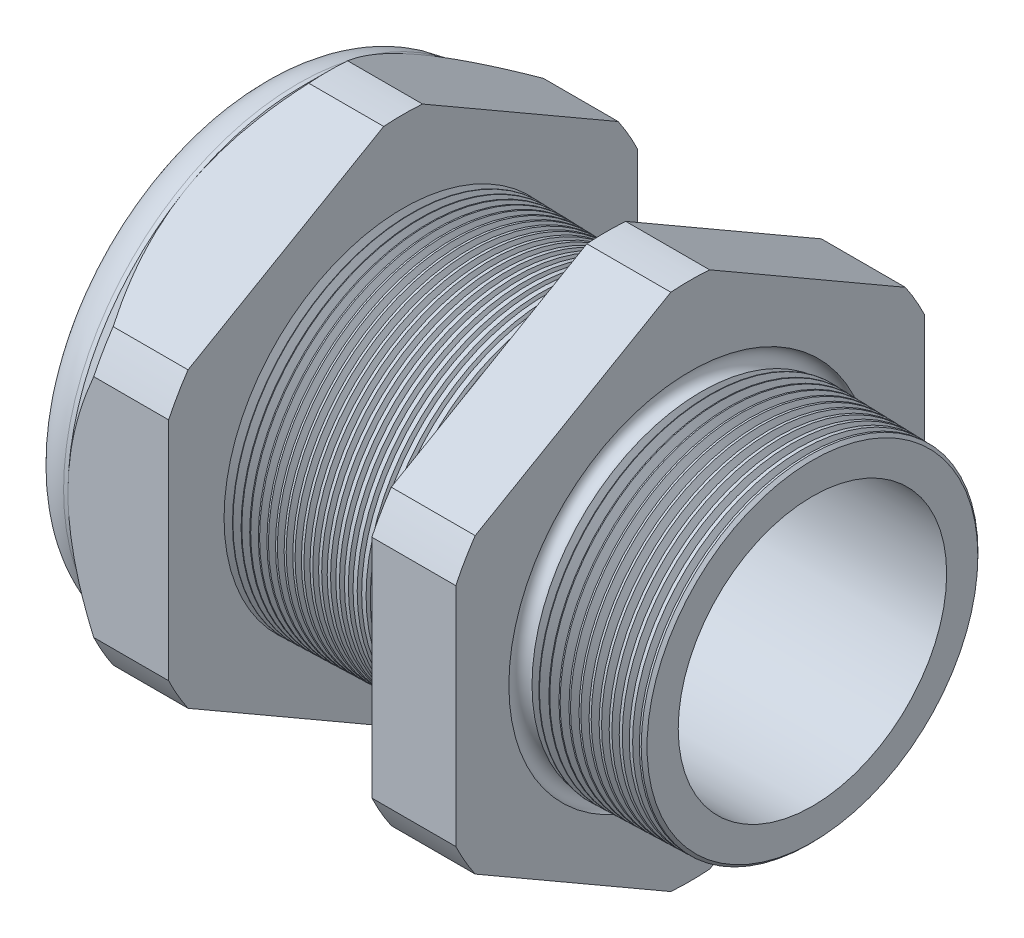
from build123d import *

# Parameters (mm, degrees)
SKETCH12_OUTSIDE_W = 111.534
SKETCH12_OUTSIDE_H = 111.534
CUT_EXTRUDE2_DEPTH = 46.584
FILLET4_R          = 3.81
SKETCH19_OUTSIDE_W = 67.904
SKETCH19_OUTSIDE_H = 72.514
SKETCH19_OUTSIDE_R = 20.955
CUT_EXTRUDE3_DEPTH = 3.99796
CUT_EXTRUDE3_DRAFT = -45
CHAMFER1_SIZE      = 0.260919487
CHAMFER1_SIZE2     = 0.254
SKETCH21_R         = 12.446
PLUG_DEPTH         = 12.7
SKETCH22_R         = 12.192
CUT_EXTRUDE4_DEPTH = 0.508
SKETCH27_R         = 3.302
PLUGHOLES_DEPTH    = 50.276
CIRPATTERN1_COUNT  = 6
LPATTERN1_COUNT    = 24
LPATTERN1_PITCH    = 0.762
LPATTERN2_COUNT    = 12
LPATTERN2_PITCH    = 0.889
SKETCH32_R         = 0.889


with BuildPart() as part:
    # Sketch10 → Revolve2 (revolve)
    with BuildSketch(Plane.XY, mode=Mode.PRIVATE) as revolve2_sk:
        Polygon((-46.736, 12.446), (-33.536, 12.446), (3.048, 11.996014245), (3.048, 15.044014245), (-7.874, 15.330016881), (-7.874, 41.91), (-15.374, 41.91), (-15.374, 15.526411292), (-33.536, 16.002), (-33.536, 41.91), (-42.536, 41.91), (-42.536, 20.955), (-46.736, 20.955), align=None)
    revolve(revolve2_sk.sketch.rotate(Axis((0, 0, 0), (-1, 0, 0)), 90), axis=Axis((0, 0, 0), (-1, 0, 0)))  # turned: the seam where the file's is

    # Sketch12 outside → Cut-Extrude2 (cut, through all)
    with BuildSketch(Plane.ZY.offset(42.536)):
        Rectangle(SKETCH12_OUTSIDE_W, SKETCH12_OUTSIDE_H)
        with BuildLine():
            Line((-1.734592832, 23.195282143), (-19.220407168, 13.099842529))
            ThreePointArc((-19.220407168, 13.099842529), (-20.143794193, 11.630025), (-20.955, 10.095439614))
            Line((-20.955, 10.095439614), (-20.955, -10.095439614))
            ThreePointArc((-20.955, -10.095439614), (-20.143794193, -11.630025), (-19.220407168, -13.099842529))
            Line((-19.220407168, -13.099842529), (-1.734592832, -23.195282143))
            ThreePointArc((-1.734592832, -23.195282143), (0, -23.26005), (1.734592832, -23.195282143))
            Line((1.734592832, -23.195282143), (19.220407168, -13.099842529))
            ThreePointArc((19.220407168, -13.099842529), (20.143794193, -11.630025), (20.955, -10.095439614))
            Line((20.955, -10.095439614), (20.955, 10.095439614))
            ThreePointArc((20.955, 10.095439614), (20.143794193, 11.630025), (19.220407168, 13.099842529))
            Line((19.220407168, 13.099842529), (1.734592832, 23.195282143))
            ThreePointArc((1.734592832, 23.195282143), (0, 23.26005), (-1.734592832, 23.195282143))
        make_face(mode=Mode.SUBTRACT)
    extrude(amount=-CUT_EXTRUDE2_DEPTH, mode=Mode.SUBTRACT)

    # Fillet4
    fillet4_edges = [part.edges().sort_by_distance(p)[0] for p in [
        (-46.736, 0, 20.955),
    ]]
    fillet(fillet4_edges, radius=FILLET4_R)


with BuildPart() as cut_extrude3_tool:
    # Sketch19 outside → Cut-Extrude3 (with draft: the straight prism first)
    with BuildSketch(Plane.ZY.offset(42.536)):
        Rectangle(SKETCH19_OUTSIDE_W, SKETCH19_OUTSIDE_H)
        Circle(SKETCH19_OUTSIDE_R, mode=Mode.SUBTRACT)
    extrude(amount=-CUT_EXTRUDE3_DEPTH)
    # Cut-Extrude3: the draft: its side faces are tilted about the plane it starts from
    cut_extrude3_sides = [cut_extrude3_tool.faces().sort_by_distance(p)[0] for p in [
        (-40.53702, -36.257, 0),
        (-40.53702, 0, 33.952),
        (-40.53702, 36.257, 0),
        (-40.53702, 0, -33.952),
        (-40.53702, 0, -20.955),
    ]]
    draft(cut_extrude3_sides, Plane.ZY.offset(42.536), CUT_EXTRUDE3_DRAFT)


with BuildPart() as part_1:
    add(part.part)

    # Cut-Extrude3: cut by cut_extrude3_tool
    add(cut_extrude3_tool.part, mode=Mode.SUBTRACT)

    # Chamfer1
    chamfer1_edges = [part_1.edges().sort_by_distance(p)[0] for p in [
        (3.048, 0, 15.044014245),
    ]]
    chamfer1_side = [part_1.faces().sort_by_distance(p)[0] for p in [
        (3.048, 0, 12.421523225),
    ]]
    chamfer(chamfer1_edges, length=CHAMFER1_SIZE, length2=CHAMFER1_SIZE2, reference=chamfer1_side[0])

    # Sketch29 → Cut-Revolve1 (revolve, cut)
    with BuildSketch(Plane.XY, mode=Mode.PRIVATE) as cut_revolve1_sk:
        Polygon((-33.536, 16.002), (-32.803016419, 15.982806149), (-33.186130572, 15.357620673), align=None)
    cut_revolve1 = revolve(cut_revolve1_sk.sketch.rotate(Axis((0, 0, 0), (-1, 0, 0)), 90), axis=Axis((0, 0, 0), (-1, 0, 0)), mode=Mode.SUBTRACT)  # turned: the seam where the file's is

    # LPattern1: Cut-Revolve1 ×24
    with Locations(*[(i * LPATTERN1_PITCH, 0, 0) for i in range(1, LPATTERN1_COUNT)]):
        add(cut_revolve1, mode=Mode.SUBTRACT)

    # Sketch30 → Cut-Revolve2 (revolve, cut)
    with BuildSketch(Plane.XY, mode=Mode.PRIVATE) as cut_revolve2_sk:
        Polygon((-7.874, 15.330016881), (-6.994419703, 15.30698426), (-7.454156686, 14.556761689), align=None)
    cut_revolve2 = revolve(cut_revolve2_sk.sketch.rotate(Axis((0, 0, 0), (-1, 0, 0)), 270), axis=Axis((0, 0, 0), (-1, 0, 0)), mode=Mode.SUBTRACT)  # turned: the seam where the file's is

    # LPattern2: Cut-Revolve2 ×12
    with Locations(*[(i * LPATTERN2_PITCH, 0, 0) for i in range(1, LPATTERN2_COUNT)]):
        add(cut_revolve2, mode=Mode.SUBTRACT)

    # Sketch32 → Cut-Revolve3 (revolve, cut)
    with BuildSketch(Plane.XY, mode=Mode.PRIVATE) as cut_revolve3_sk:
        with Locations((-7.747, 15.330016881)):
            Circle(SKETCH32_R)
    revolve(cut_revolve3_sk.sketch.rotate(Axis((0, 0, 0), (-1, 0, 0)), 270), axis=Axis((0, 0, 0), (-1, 0, 0)), mode=Mode.SUBTRACT)  # turned: the seam where the file's is


with BuildPart() as body_2:
    # Sketch21 → plug (new body)
    with BuildSketch(Plane.ZY.offset(46.736)):
        Circle(SKETCH21_R)
    extrude(amount=-PLUG_DEPTH)

    # Sketch22 → Cut-Extrude4 (cut)
    with BuildSketch(Plane.ZY.offset(46.736)):
        Circle(SKETCH22_R)
    extrude(amount=-CUT_EXTRUDE4_DEPTH, mode=Mode.SUBTRACT)

    # Sketch27 → plugholes (cut, through all)
    with BuildSketch(Plane.ZY.offset(46.228)):
        with Locations((-8.876792, 0)):
            Circle(SKETCH27_R)
    plugholes = extrude(amount=-PLUGHOLES_DEPTH, mode=Mode.SUBTRACT)

    # CirPattern1: plugholes ×6 about axis
    cirpattern1_axis = Axis((0, 0, 0), (1, 0, 0))
    for i in range(1, CIRPATTERN1_COUNT):
        add(plugholes.rotate(cirpattern1_axis, i * 360 / CIRPATTERN1_COUNT), mode=Mode.SUBTRACT)


solid = Compound([part_1.part, body_2.part])
